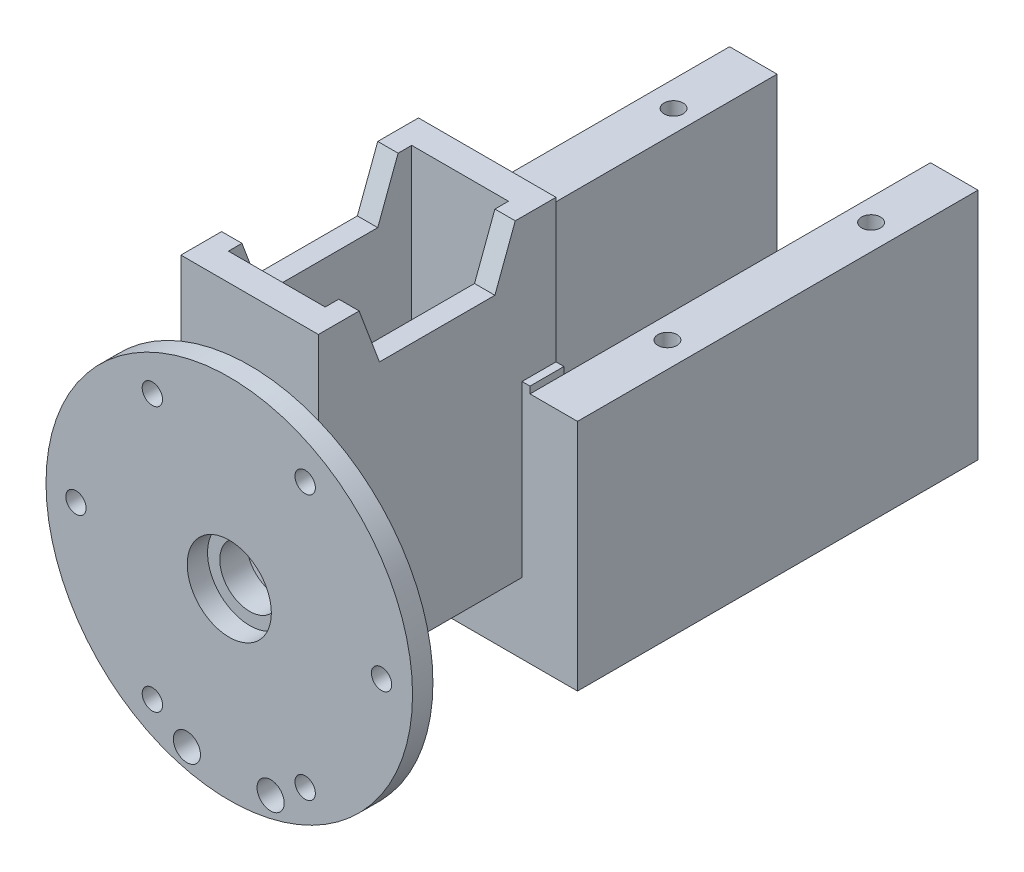
from build123d import *

# Parameters (mm, degrees)
EXTRUDE_1_DEPTH     = 13.5
SKETCH_1_3_W        = 20.26
SKETCH_1_3_H        = 46
SKETCH_1_3_R        = 4.4
EXTRUDE_2_DEPTH     = 4
CUT_EXTRUDE_1_DEPTH = 40
CUT_EXTRUDE_2_DEPTH = 0.5
SKETCH_4_R          = 27
SKETCH_4_R_2        = 6.2
SKETCH_4_R_3        = 2
SKETCH_4_R_4        = 1.5
EXTRUDE_3_DEPTH     = 3
SKETCH_8_W          = 2.265156823
SKETCH_8_H          = 4.257571482
CUT_EXTRUDE_4_DEPTH = 30
EXTRUDE_11_DEPTH    = 5
EXTRUDE_12_DEPTH    = 5
EXTRUDE_13_DEPTH    = 54
SKETCH_13_R         = 1.4
CUT_EXTRUDE_5_DEPTH = 5
SKETCH_14_R         = 1.4
CUT_EXTRUDE_6_DEPTH = 5


with BuildPart() as part:
    # 草图1 → 凸台-拉伸1 (new body)
    with BuildSketch(Plane.XY):
        Polygon((4.13, -7), (-4.13, -7), (-7.13, -4), (-7.13, 36), (-10.13, 36), (-10.13, -10), (10.13, -10), (10.13, 36), (7.13, 36), (7.13, -4), align=None)
    extrude_1 = extrude(amount=EXTRUDE_1_DEPTH)

    # 草图1<3> → 凸台-拉伸2 (add)
    with BuildSketch(Plane.XY):
        with Locations((0, 13)):
            Rectangle(SKETCH_1_3_W, SKETCH_1_3_H)
        Circle(SKETCH_1_3_R, mode=Mode.SUBTRACT)
    extrude_2 = extrude(amount=-EXTRUDE_2_DEPTH)

    # 镜向1: 凸台-拉伸1, 凸台-拉伸2 across plane
    add(extrude_1.mirror(Plane.XY.offset(13.5)))
    add(extrude_2.mirror(Plane.XY.offset(13.5)))

    # 草图2 → 切除-拉伸1 (cut)
    with BuildSketch(Plane.ZY.offset(10.13)):
        Polygon((2, 36), (5, 28), (22, 28), (25, 36), align=None)
    extrude(amount=-CUT_EXTRUDE_1_DEPTH, mode=Mode.SUBTRACT)

    # 草图3 → 切除-拉伸2 (cut)
    with BuildSketch(Plane.ZY.offset(10.13)):
        Polygon((5, 12), (17.297318311, 12), (17.297318311, 16), (22, 10.5), (17.297318311, 5), (17.297318311, 9), (5, 9), align=None)
    extrude(amount=-CUT_EXTRUDE_2_DEPTH, mode=Mode.SUBTRACT)

    # 草图4 → 凸台-拉伸3 (add)
    with BuildSketch(Plane.XY.offset(31)):
        Circle(SKETCH_4_R)
        Circle(SKETCH_4_R_2, mode=Mode.SUBTRACT)
        with Locations((6.088327702, -23.309373565)):
            Circle(SKETCH_4_R_3, mode=Mode.SUBTRACT)
        with Locations((22.434887901, -0.282877885)):
            Circle(SKETCH_4_R_4, mode=Mode.SUBTRACT)
        with Locations((11.179706516, 19.211668123)):
            Circle(SKETCH_4_R_4, mode=Mode.SUBTRACT)
        with Locations((-11.330656255, 19.211668123)):
            Circle(SKETCH_4_R_4, mode=Mode.SUBTRACT)
        with Locations((-22.58583764, -0.282877885)):
            Circle(SKETCH_4_R_4, mode=Mode.SUBTRACT)
        with Locations((-11.330656255, -19.777423893)):
            Circle(SKETCH_4_R_4, mode=Mode.SUBTRACT)
        with Locations((11.179706516, -19.777423893)):
            Circle(SKETCH_4_R_4, mode=Mode.SUBTRACT)
        with Locations((-6.239277441, -23.309373565)):
            Circle(SKETCH_4_R_3, mode=Mode.SUBTRACT)
    extrude(amount=EXTRUDE_3_DEPTH)

    # 草图8 → 切除-拉伸4 (cut)
    with BuildSketch(Plane(origin=(-10.13, 0, 0.991647231), x_dir=(0, 0, 1), z_dir=(-1, 0, 0))):
        with Locations((28.867421589, 19.251576228)):
            Rectangle(SKETCH_8_W, SKETCH_8_H)
    extrude(amount=-CUT_EXTRUDE_4_DEPTH, mode=Mode.SUBTRACT)

    # 草图11 → 凸台-拉伸11 (add)
    with BuildSketch(Plane(origin=(0, 0, -4), x_dir=(-1, 0, 0), z_dir=(0, 0, -1))):
        Polygon((10.13, 15), (10.13, -10), (-10.13, -10), (-10.13, 15), (-11.3, 15), (-11.3, -15), (11.3, -15), (11.3, 15), align=None)
    extrude(amount=-EXTRUDE_11_DEPTH)

    # 草图11<3> → 凸台-拉伸12 (add)
    with BuildSketch(Plane(origin=(0, 0, -4), x_dir=(-1, 0, 0), z_dir=(0, 0, -1))):
        Polygon((11.3, 14), (11.3, 0), (11.3, -15), (-11.3, -15), (-11.3, 14), (-18.3, 14), (-18.3, -17.416972989), (-18.3, -20.416972989), (18.3, -20.416972989), (18.3, 14), align=None)
    extrude(amount=-EXTRUDE_12_DEPTH)

    # 草图11<4> → 凸台-拉伸13 (add)
    with BuildSketch(Plane(origin=(0, 0, -4), x_dir=(-1, 0, 0), z_dir=(0, 0, -1))):
        Polygon((11.3, 14), (11.3, 0), (11.3, -15), (-11.3, -15), (-11.3, 14), (-18.3, 14), (-18.3, -17.416972989), (-18.3, -20.416972989), (18.3, -20.416972989), (18.3, 14), align=None)
    extrude(amount=EXTRUDE_13_DEPTH)

    # 草图13 → 切除-拉伸5 (cut)
    with BuildSketch(Plane(origin=(0, 14, 0), x_dir=(1, 0, 0), z_dir=(0, 1, 0))):
        with Locations((-14.55, 16)):
            Circle(SKETCH_13_R)
        with Locations((-14.55, 46)):
            Circle(SKETCH_13_R)
    extrude(amount=-CUT_EXTRUDE_5_DEPTH, mode=Mode.SUBTRACT)

    # 草图14 → 切除-拉伸6 (cut)
    with BuildSketch(Plane(origin=(0, 14, 0), x_dir=(1, 0, 0), z_dir=(0, 1, 0))):
        with Locations((14.55, 16)):
            Circle(SKETCH_14_R)
        with Locations((14.55, 46)):
            Circle(SKETCH_14_R)
    extrude(amount=-CUT_EXTRUDE_6_DEPTH, mode=Mode.SUBTRACT)


solid = part.part
